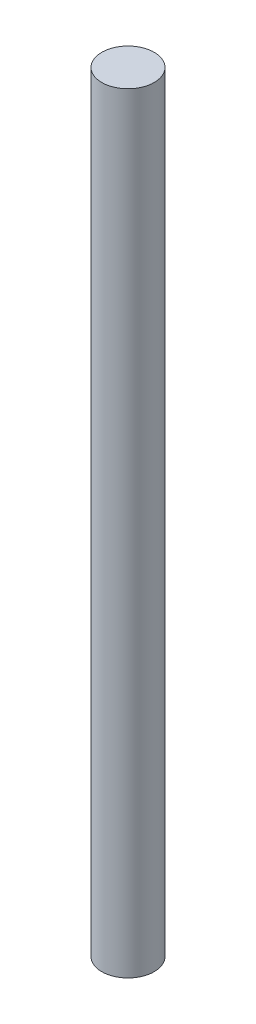
from build123d import *

# Parameters (mm, degrees)
SKETCH1_R           = 2.5
BOSS_EXTRUDE1_DEPTH = 73.5


with BuildPart() as part:
    # Sketch1 → Boss-Extrude1 (new body)
    with BuildSketch(Plane(origin=(0, 0, 0), x_dir=(1, 0, 0), z_dir=(0, 1, 0))):
        Circle(SKETCH1_R)
    extrude(amount=BOSS_EXTRUDE1_DEPTH)


solid = part.part
